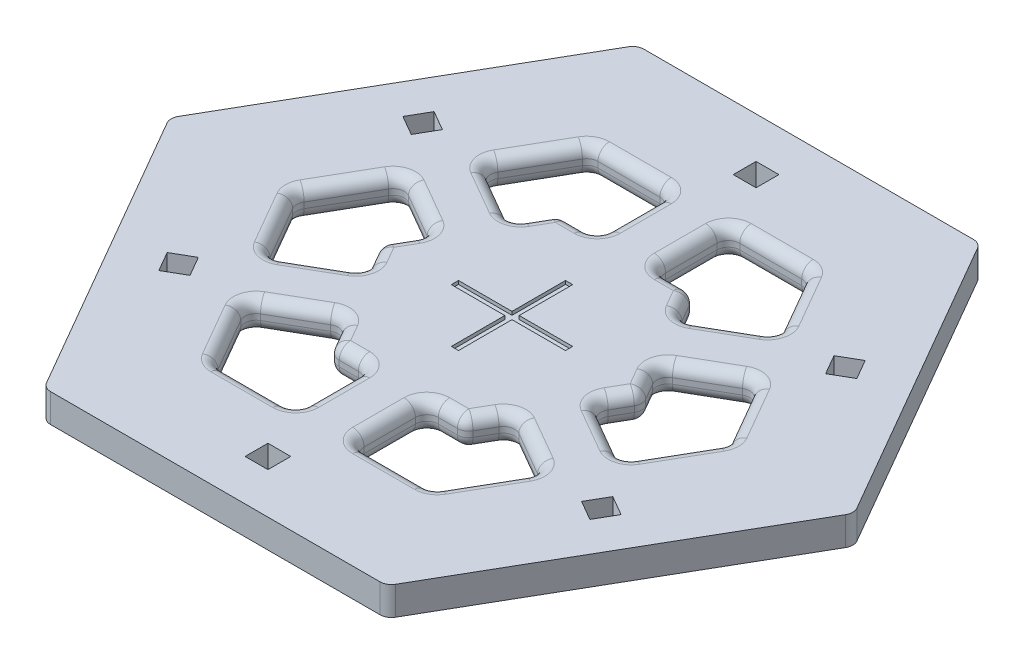
from build123d import *

# Parameters (mm, degrees)
BOSS_EXTRUDE1_DEPTH = 6.35
SKETCH3_W           = 5.08
SKETCH3_H           = 5.08
CUT_EXTRUDE2_DEPTH  = 62.484
FILLET1_R           = 2.54
FILLET2_R           = 2.54
FILLET3_R           = 2.54
FILLET4_R           = 2.54
FILLET5_R           = 2.54
FILLET6_R           = 2.54
FILLET7_R           = 2.54
SKETCH4_W           = 11.902368967
SKETCH4_H           = 1.595262066
SKETCH4_W_2         = 1.595262066
SKETCH4_H_2         = 11.902368967
CUT_EXTRUDE4_DEPTH  = 0.762


with BuildPart() as part:
    # Sketch1 → Boss-Extrude1 (new body)
    with BuildSketch(Plane(origin=(0, 0, 0), x_dir=(1, 0, 0), z_dir=(0, 1, 0))):
        Polygon((76.2, 0), (38.1, 65.991135768), (-38.1, 65.991135768), (-76.2, 0), (-38.1, -65.991135768), (38.1, -65.991135768), align=None)
        with BuildLine():
            Line((48.26, 0), (40.64, 13.198227154))
            ThreePointArc((40.64, 13.198227154), (39.097695849, 14.381678752), (37.170295474, 14.127931679))
            Line((37.170295474, 14.127931679), (25.0825, 7.149039708))
            Line((25.0825, 7.149039708), (29.21, 0))
            Line((29.21, 0), (25.0825, -7.149039708))
            Line((25.0825, -7.149039708), (37.170295474, -14.127931679))
            ThreePointArc((37.170295474, -14.127931679), (39.097695849, -14.381678752), (40.64, -13.198227154))
            Line((40.64, -13.198227154), (48.26, 0))
        make_face(mode=Mode.SUBTRACT)
        with BuildLine():
            Line((24.13, 41.794385987), (8.89, 41.794385987))
            ThreePointArc((8.89, 41.794385987), (7.093948776, 41.050437211), (6.35, 39.254385987))
            Line((6.35, 39.254385987), (6.35, 25.296602045))
            Line((6.35, 25.296602045), (14.605, 25.296602045))
            Line((14.605, 25.296602045), (18.7325, 18.147562336))
            Line((18.7325, 18.147562336), (30.820295474, 25.126454307))
            ThreePointArc((30.820295474, 25.126454307), (32.003747073, 26.668758458), (31.75, 28.596158833))
            Line((31.75, 28.596158833), (24.13, 41.794385987))
        make_face(mode=Mode.SUBTRACT)
        with BuildLine():
            Line((-24.13, 41.794385987), (-31.75, 28.596158833))
            ThreePointArc((-31.75, 28.596158833), (-32.003747073, 26.668758458), (-30.820295474, 25.126454307))
            Line((-30.820295474, 25.126454307), (-18.7325, 18.147562336))
            Line((-18.7325, 18.147562336), (-14.605, 25.296602045))
            Line((-14.605, 25.296602045), (-6.35, 25.296602045))
            Line((-6.35, 25.296602045), (-6.35, 39.254385987))
            ThreePointArc((-6.35, 39.254385987), (-7.093948776, 41.050437211), (-8.89, 41.794385987))
            Line((-8.89, 41.794385987), (-24.13, 41.794385987))
        make_face(mode=Mode.SUBTRACT)
        with BuildLine():
            Line((-48.26, 0), (-40.64, -13.198227154))
            ThreePointArc((-40.64, -13.198227154), (-39.097695849, -14.381678752), (-37.170295474, -14.127931679))
            Line((-37.170295474, -14.127931679), (-25.0825, -7.149039708))
            Line((-25.0825, -7.149039708), (-29.21, 0))
            Line((-29.21, 0), (-25.0825, 7.149039708))
            Line((-25.0825, 7.149039708), (-37.170295474, 14.127931679))
            ThreePointArc((-37.170295474, 14.127931679), (-39.097695849, 14.381678752), (-40.64, 13.198227154))
            Line((-40.64, 13.198227154), (-48.26, 0))
        make_face(mode=Mode.SUBTRACT)
        with BuildLine():
            Line((-24.13, -41.794385987), (-8.89, -41.794385987))
            ThreePointArc((-8.89, -41.794385987), (-7.093948776, -41.050437211), (-6.35, -39.254385987))
            Line((-6.35, -39.254385987), (-6.35, -25.296602045))
            Line((-6.35, -25.296602045), (-14.605, -25.296602045))
            Line((-14.605, -25.296602045), (-18.7325, -18.147562336))
            Line((-18.7325, -18.147562336), (-30.820295474, -25.126454307))
            ThreePointArc((-30.820295474, -25.126454307), (-32.003747073, -26.668758458), (-31.75, -28.596158833))
            Line((-31.75, -28.596158833), (-24.13, -41.794385987))
        make_face(mode=Mode.SUBTRACT)
        with BuildLine():
            Line((24.13, -41.794385987), (31.75, -28.596158833))
            ThreePointArc((31.75, -28.596158833), (32.003747073, -26.668758458), (30.820295474, -25.126454307))
            Line((30.820295474, -25.126454307), (18.7325, -18.147562336))
            Line((18.7325, -18.147562336), (14.605, -25.296602045))
            Line((14.605, -25.296602045), (6.35, -25.296602045))
            Line((6.35, -25.296602045), (6.35, -39.254385987))
            ThreePointArc((6.35, -39.254385987), (7.093948776, -41.050437211), (8.89, -41.794385987))
            Line((8.89, -41.794385987), (24.13, -41.794385987))
        make_face(mode=Mode.SUBTRACT)
    extrude(amount=BOSS_EXTRUDE1_DEPTH)

    # Sketch3 → Cut-Extrude2 (cut)
    with BuildSketch(Plane(origin=(0, 6.35, 0), x_dir=(1, 0, 0), z_dir=(0, 1, 0))):
        with Locations((0, 54.300240495)):
            Rectangle(SKETCH3_W, SKETCH3_H)
        Polygon((47.955092226, 30.619824773), (50.495092226, 26.220415722), (46.095683175, 23.680415722), (43.555683175, 28.079824773), align=None)
        Polygon((50.495092226, -26.220415722), (47.955092226, -30.619824773), (43.555683175, -28.079824773), (46.095683175, -23.680415722), align=None)
        with Locations((0, -54.300240495)):
            Rectangle(SKETCH3_W, SKETCH3_H)
        Polygon((-47.955092226, -30.619824773), (-50.495092226, -26.220415722), (-46.095683175, -23.680415722), (-43.555683175, -28.079824773), align=None)
        Polygon((-47.955092226, 30.619824773), (-43.555683175, 28.079824773), (-46.095683175, 23.680415722), (-50.495092226, 26.220415722), align=None)
    extrude(amount=-CUT_EXTRUDE2_DEPTH, mode=Mode.SUBTRACT)

    # Fillet1
    fillet1_edges = [part.edges().sort_by_distance(p)[0] for p in [
        (25.0825, 3.175, -7.149039708),
        (29.21, 3.175, 0),
        (25.0825, 3.175, 7.149039708),
        (48.26, 3.175, 0),
        (24.13, 3.175, -41.794385987),
        (6.35, 3.175, -25.296602045),
        (14.605, 3.175, -25.296602045),
        (18.7325, 3.175, -18.147562336),
        (-39.097695849, 6.35, -14.381678752),
        (-31.126397737, 6.35, -10.638485694),
        (32.003747073, 6.35, -26.668758458),
        (-27.14625, 6.35, -3.574519854),
        (-27.14625, 6.35, 3.574519854),
        (-31.126397737, 6.35, 10.638485694),
        (-39.097695849, 6.35, 14.381678752),
        (-44.45, 6.35, 6.599113577),
        (-16.51, 6.35, -41.794385987),
        (-7.093948776, 6.35, -41.050437211),
        (-6.35, 6.35, -32.275494016),
        (-10.4775, 6.35, -25.296602045),
        (-16.66875, 6.35, -21.72208219),
        (24.776397737, 6.35, -21.637008322),
        (-24.776397737, 6.35, -21.637008322),
        (-32.003747073, 6.35, -26.668758458),
        (-27.94, 6.35, -35.19527241),
        (16.51, 6.35, 41.794385987),
        (7.093948776, 6.35, 41.050437211),
        (6.35, 6.35, 32.275494016),
        (10.4775, 6.35, 25.296602045),
        (16.66875, 6.35, 21.72208219),
        (24.776397737, 6.35, 21.637008322),
        (32.003747073, 6.35, 26.668758458),
        (16.66875, 6.35, -21.72208219),
        (27.94, 6.35, 35.19527241),
        (-6.35, 6.35, 32.275494016),
        (-7.093948776, 6.35, 41.050437211),
        (-16.51, 6.35, 41.794385987),
        (-27.94, 6.35, 35.19527241),
        (-32.003747073, 6.35, 26.668758458),
        (-24.776397737, 6.35, 21.637008322),
        (-16.66875, 6.35, 21.72208219),
        (-10.4775, 6.35, 25.296602045),
        (10.4775, 6.35, -25.296602045),
        (6.35, 6.35, -32.275494016),
        (7.093948776, 6.35, -41.050437211),
        (16.51, 6.35, -41.794385987),
        (27.94, 6.35, -35.19527241),
        (39.097695849, 6.35, -14.381678752),
        (44.45, 6.35, -6.599113577),
        (44.45, 6.35, 6.599113577),
        (-10.4775, 0, 25.296602045),
        (-16.66875, 0, 21.72208219),
        (-24.776397737, 0, 21.637008322),
        (-32.003747073, 0, 26.668758458),
        (39.097695849, 6.35, 14.381678752),
        (-27.94, 0, 35.19527241),
        (-16.51, 0, 41.794385987),
        (-7.093948776, 0, 41.050437211),
        (-6.35, 0, 32.275494016),
        (27.94, 0, 35.19527241),
        (32.003747073, 0, 26.668758458),
        (24.776397737, 0, 21.637008322),
        (16.66875, 0, 21.72208219),
        (31.126397737, 6.35, 10.638485694),
        (10.4775, 0, 25.296602045),
        (6.35, 0, 32.275494016),
        (7.093948776, 0, 41.050437211),
        (16.51, 0, 41.794385987),
        (-27.94, 0, -35.19527241),
        (-32.003747073, 0, -26.668758458),
        (-24.776397737, 0, -21.637008322),
        (-16.66875, 0, -21.72208219),
        (27.14625, 6.35, 3.574519854),
        (-10.4775, 0, -25.296602045),
        (-6.35, 0, -32.275494016),
        (-7.093948776, 0, -41.050437211),
        (-16.51, 0, -41.794385987),
        (-44.45, 0, 6.599113577),
        (-39.097695849, 0, 14.381678752),
        (-31.126397737, 0, 10.638485694),
        (-27.14625, 0, 3.574519854),
        (27.14625, 6.35, -3.574519854),
        (-27.14625, 0, -3.574519854),
        (-31.126397737, 0, -10.638485694),
        (-39.097695849, 0, -14.381678752),
        (-44.45, 0, -6.599113577),
        (31.126397737, 6.35, -10.638485694),
        (31.126397737, 0, -10.638485694),
        (27.14625, 0, -3.574519854),
        (27.14625, 0, 3.574519854),
        (31.126397737, 0, 10.638485694),
        (39.097695849, 0, 14.381678752),
        (44.45, 0, 6.599113577),
        (44.45, 0, -6.599113577),
        (39.097695849, 0, -14.381678752),
        (27.94, 0, -35.19527241),
        (16.51, 0, -41.794385987),
        (7.093948776, 0, -41.050437211),
        (6.35, 0, -32.275494016),
        (10.4775, 0, -25.296602045),
        (16.66875, 0, -21.72208219),
        (24.776397737, 0, -21.637008322),
        (32.003747073, 0, -26.668758458),
        (-6.35, 3.175, 25.296602045),
        (-14.605, 3.175, 25.296602045),
        (-18.7325, 3.175, 18.147562336),
        (-24.13, 3.175, 41.794385987),
        (24.13, 3.175, 41.794385987),
        (18.7325, 3.175, 18.147562336),
        (14.605, 3.175, 25.296602045),
        (6.35, 3.175, 25.296602045),
        (-24.13, 3.175, -41.794385987),
        (-18.7325, 3.175, -18.147562336),
        (-14.605, 3.175, -25.296602045),
        (-6.35, 3.175, -25.296602045),
        (-44.45, 6.35, -6.599113577),
        (-48.26, 3.175, 0),
        (-25.0825, 3.175, 7.149039708),
        (-29.21, 3.175, 0),
        (-25.0825, 3.175, -7.149039708),
    ]]
    fillet(fillet1_edges, radius=FILLET1_R)

    # Fillet2
    fillet2_edges = [part.edges().sort_by_distance(p)[0] for p in [
        (-38.1, 3.175, 65.991135768),
    ]]
    fillet(fillet2_edges, radius=FILLET2_R)

    # Fillet3
    fillet3_edges = [part.edges().sort_by_distance(p)[0] for p in [
        (38.1, 3.175, 65.991135768),
    ]]
    fillet(fillet3_edges, radius=FILLET3_R)

    # Fillet4
    fillet4_edges = [part.edges().sort_by_distance(p)[0] for p in [
        (76.2, 3.175, 0),
    ]]
    fillet(fillet4_edges, radius=FILLET4_R)

    # Fillet5
    fillet5_edges = [part.edges().sort_by_distance(p)[0] for p in [
        (38.1, 3.175, -65.991135768),
    ]]
    fillet(fillet5_edges, radius=FILLET5_R)

    # Fillet6
    fillet6_edges = [part.edges().sort_by_distance(p)[0] for p in [
        (-38.1, 3.175, -65.991135768),
    ]]
    fillet(fillet6_edges, radius=FILLET6_R)

    # Fillet7
    fillet7_edges = [part.edges().sort_by_distance(p)[0] for p in [
        (-76.2, 3.175, 0),
    ]]
    fillet(fillet7_edges, radius=FILLET7_R)

    # Sketch4 → Cut-Extrude4 (cut)
    with BuildSketch(Plane(origin=(0, 6.35, 0), x_dir=(1, 0, 0), z_dir=(0, 1, 0))):
        with Locations((-6.748815517, 0)):
            Rectangle(SKETCH4_W, SKETCH4_H)
        with Locations((0, -6.748815517)):
            Rectangle(SKETCH4_W_2, SKETCH4_H_2)
        Rectangle(SKETCH4_W_2, SKETCH4_H)
        with Locations((6.748815517, 0)):
            Rectangle(SKETCH4_W, SKETCH4_H)
        with Locations((0, 6.748815517)):
            Rectangle(SKETCH4_W_2, SKETCH4_H_2)
    extrude(amount=-CUT_EXTRUDE4_DEPTH, mode=Mode.SUBTRACT)


solid = part.part
